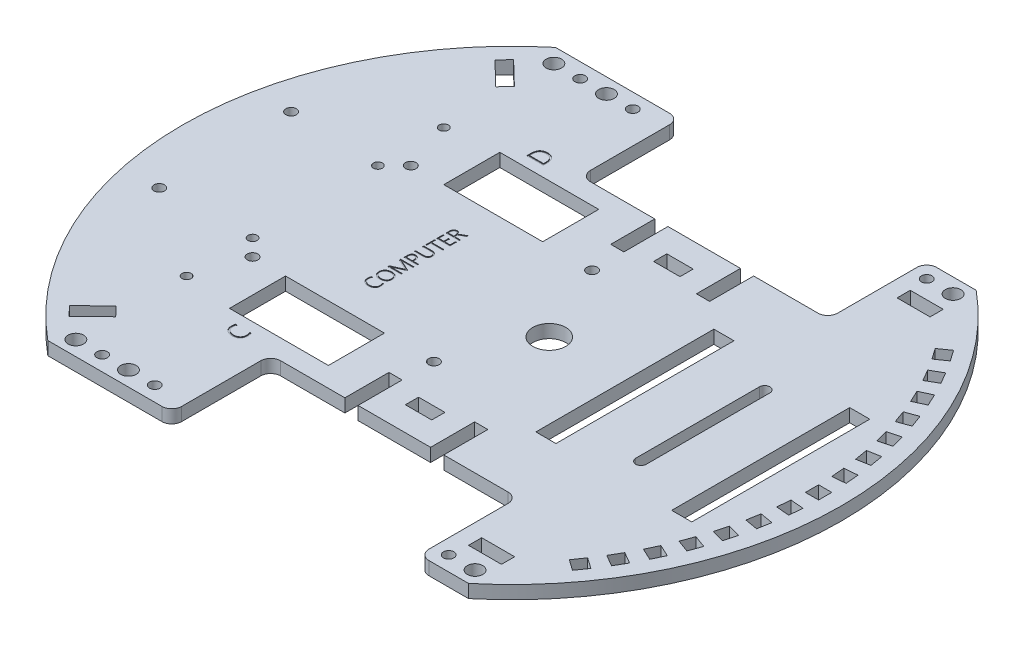
from build123d import *

# Parameters (mm, degrees)
BASIS_DEPTH         = 4
SKETCH2_W           = 4
SKETCH2_H           = 4
MODU_BRACKET_DEPTH  = 4
SKETCH3_R           = 5
SKETCH3_W           = 75
SKETCH3_H           = 30
SKETCH3_W_2         = 8
SKETCH3_H_2         = 4
CUT_EXTRUDE2_DEPTH  = 5
SKETCH4_W           = 6.1
SKETCH4_H           = 54
CUT_EXTRUDE3_DEPTH  = 4
SKETCH5_W           = 4
SKETCH5_H           = 14
CUT_EXTRUDE4_DEPTH  = 4
SKETCH6_W           = 10
SKETCH6_H           = 4
CUT_EXTRUDE5_DEPTH  = 4
SKETCH9_R           = 1.6
SKETCH9_R_2         = 1.375
CUT_EXTRUDE7_DEPTH  = 4
SKETCH10_W          = 30
SKETCH10_H          = 17
CUT_EXTRUDE8_DEPTH  = 4
SKETCH11_R          = 1.6
CUT_EXTRUDE9_DEPTH  = 4
CUT_EXTRUDE15_DEPTH = 0.2
SKETCH21_R          = 2.35
SKETCH21_R_2        = 1.6
CUT_EXTRUDE16_DEPTH = 4
FILLET1_R           = 3


with BuildPart() as part:
    # Sketch1 → Basis (new body)
    with BuildSketch(Plane(origin=(0, 0, 0), x_dir=(1, 0, 0), z_dir=(0, 1, 0))):
        with BuildLine():
            Line((63.804388564, 77), (-63.804388564, 77))
            ThreePointArc((-63.804388564, 77), (-100, 0), (-63.804388564, -77))
            Line((-63.804388564, -77), (63.804388564, -77))
            ThreePointArc((63.804388564, -77), (90.499831095, -42.541515862), (100, 0))
            ThreePointArc((100, 0), (90.499831095, 42.541515862), (63.804388564, 77))
        make_face()
    extrude(amount=BASIS_DEPTH)

    # Sketch2 → Modu bracket (cut)
    with BuildSketch(Plane(origin=(0, 4, 0), x_dir=(1, 0, 0), z_dir=(0, 1, 0))):
        Polygon((90.817009036, -6.191182133), (94.801787829, -6.539805104), (94.453164858, -10.524583897), (90.468386065, -10.175960926), align=None)
        with Locations((93, 0)):
            Rectangle(SKETCH2_W, SKETCH2_H)
        Polygon((89.920805845, -14.335245632), (93.860036857, -15.029838343), (93.165444147, -18.969069355), (89.226213135, -18.274476644), align=None)
        Polygon((88.318211075, -22.370209256), (92.18191438, -23.405485436), (91.1466382, -27.269188741), (87.282934895, -26.233912561), align=None)
        Polygon((86.021421439, -30.23492208), (89.780191922, -31.603002653), (88.412111349, -35.361773136), (84.653340866, -33.993692563), align=None)
        Polygon((83.047916894, -37.86952889), (86.673148042, -39.560001937), (84.982674995, -43.185233085), (81.357443847, -41.494760038), align=None)
        Polygon((79.420327603, -45.21592572), (82.884429218, -47.21592572), (80.884429218, -50.680027335), (77.420327603, -48.680027335), align=None)
        Polygon((75.166261713, -52.218202052), (78.442869891, -54.512507797), (76.148564145, -57.789115975), (72.871955968, -55.494810229), align=None)
        Polygon((90.468386065, 10.175960926), (94.453164858, 10.524583897), (94.801787829, 6.539805104), (90.817009036, 6.191182133), align=None)
        Polygon((89.226213135, 18.274476644), (93.165444147, 18.969069355), (93.860036857, 15.029838343), (89.920805845, 14.335245632), align=None)
        Polygon((87.282934895, 26.233912561), (91.1466382, 27.269188741), (92.18191438, 23.405485436), (88.318211075, 22.370209256), align=None)
        Polygon((84.653340866, 33.993692563), (88.412111349, 35.361773136), (89.780191922, 31.603002653), (86.021421439, 30.23492208), align=None)
        Polygon((81.357443847, 41.494760038), (84.982674995, 43.185233085), (86.673148042, 39.560001937), (83.047916894, 37.86952889), align=None)
        Polygon((77.420327603, 48.680027335), (80.884429218, 50.680027335), (82.884429218, 47.21592572), (79.420327603, 45.21592572), align=None)
        Polygon((72.871955968, 55.494810229), (76.148564145, 57.789115975), (78.44286989, 54.512507797), (75.166261713, 52.218202052), align=None)
    extrude(amount=-MODU_BRACKET_DEPTH, mode=Mode.SUBTRACT)

    # Sketch3 → Cut-Extrude2 (cut, through all)
    with BuildSketch(Plane(origin=(0, 4, 0), x_dir=(1, 0, 0), z_dir=(0, 1, 0))):
        with Locations((11.304388564, 0)):
            Circle(SKETCH3_R)
        with Locations((11.304388564, -62)):
            Rectangle(SKETCH3_W, SKETCH3_H)
        with Locations((11.304388564, 62)):
            Rectangle(SKETCH3_W, SKETCH3_H)
        with Locations((11.304388564, -37.65)):
            Rectangle(SKETCH3_W_2, SKETCH3_H_2)
        with Locations((11.304388564, 37.65)):
            Rectangle(SKETCH3_W_2, SKETCH3_H_2)
    extrude(amount=-CUT_EXTRUDE2_DEPTH, mode=Mode.SUBTRACT)

    # Sketch4 → Cut-Extrude3 (cut)
    with BuildSketch(Plane(origin=(0, 4, 0), x_dir=(1, 0, 0), z_dir=(0, 1, 0))):
        with BuildLine():
            Line((56.282145861, -18.75), (56.282145861, 18.75))
            ThreePointArc((56.282145861, 18.75), (57.882145861, 20.35), (59.482145861, 18.75))
            Line((59.482145861, 18.75), (59.482145861, -18.75))
            ThreePointArc((59.482145861, -18.75), (57.882145861, -20.35), (56.282145861, -18.75))
        make_face()
        with Locations((78.482145861, 0)):
            Rectangle(SKETCH4_W, SKETCH4_H)
        with Locations((37.282145861, 0)):
            Rectangle(SKETCH4_W, SKETCH4_H)
    extrude(amount=-CUT_EXTRUDE3_DEPTH, mode=Mode.SUBTRACT)

    # Sketch5 → Cut-Extrude4 (cut)
    with BuildSketch(Plane(origin=(0, 4, 0), x_dir=(1, 0, 0), z_dir=(0, 1, 0))):
        with Locations((-1.695611436, -40.64)):
            Rectangle(SKETCH5_W, SKETCH5_H)
        with Locations((-1.695611436, 40.64)):
            Rectangle(SKETCH5_W, SKETCH5_H)
        with Locations((24.304388564, 40.64)):
            Rectangle(SKETCH5_W, SKETCH5_H)
        with Locations((24.304388564, -40.64)):
            Rectangle(SKETCH5_W, SKETCH5_H)
    extrude(amount=-CUT_EXTRUDE4_DEPTH, mode=Mode.SUBTRACT)

    # Sketch6 → Cut-Extrude5 (cut)
    with BuildSketch(Plane(origin=(0, 4, 0), x_dir=(1, 0, 0), z_dir=(0, 1, 0))):
        Polygon((-62.518054096, 57.592655881), (-59.739420614, 60.470015082), (-66.932818617, 67.416598787), (-69.711452099, 64.539239585), align=None)
        Polygon((-59.739420614, -60.470015082), (-62.518054096, -57.592655881), (-69.711452099, -64.539239585), (-66.932818617, -67.416598787), align=None)
        with Locations((58.804388564, -65)):
            Rectangle(SKETCH6_W, SKETCH6_H)
        with Locations((58.804388564, 65)):
            Rectangle(SKETCH6_W, SKETCH6_H)
    extrude(amount=-CUT_EXTRUDE5_DEPTH, mode=Mode.SUBTRACT)

    # Sketch9 → Cut-Extrude7 (cut)
    with BuildSketch(Plane(origin=(0, 4, 0), x_dir=(1, 0, 0), z_dir=(0, 1, 0))):
        with Locations((-54.695611436, -24)):
            Circle(SKETCH9_R)
        with Locations((-54.695611436, 24)):
            Circle(SKETCH9_R)
        with Locations((0.304388564, 24)):
            Circle(SKETCH9_R)
        with Locations((0.304388564, -24)):
            Circle(SKETCH9_R)
        with Locations((-59.695611436, 39)):
            Circle(SKETCH9_R_2)
        with Locations((-59.695611436, -19)):
            Circle(SKETCH9_R_2)
        with Locations((-59.695611436, 19)):
            Circle(SKETCH9_R_2)
        with Locations((-59.695611436, -39)):
            Circle(SKETCH9_R_2)
    extrude(amount=-CUT_EXTRUDE7_DEPTH, mode=Mode.SUBTRACT)

    # Sketch10 → Cut-Extrude8 (cut)
    with BuildSketch(Plane(origin=(0, 4, 0), x_dir=(1, 0, 0), z_dir=(0, 1, 0))):
        with Locations((-29.695611436, 32.5)):
            Rectangle(SKETCH10_W, SKETCH10_H)
        with Locations((-29.695611436, -32.5)):
            Rectangle(SKETCH10_W, SKETCH10_H)
    extrude(amount=-CUT_EXTRUDE8_DEPTH, mode=Mode.SUBTRACT)

    # Sketch11 → Cut-Extrude9 (cut)
    with BuildSketch(Plane(origin=(0, 4, 0), x_dir=(1, 0, 0), z_dir=(0, 1, 0))):
        with Locations((-87, -20)):
            Circle(SKETCH11_R)
        with Locations((-87, 20)):
            Circle(SKETCH11_R)
    extrude(amount=-CUT_EXTRUDE9_DEPTH, mode=Mode.SUBTRACT)

    # Sketch19 → Cut-Extrude15 (cut)
    with BuildSketch(Plane(origin=(0, 4, 0), x_dir=(1, 0, 0), z_dir=(0, 1, 0))):
        with BuildLine():
            Line((-27.620116509, 13.789473684), (-28.764030983, 13.189967105))
            add(Edge.make_bspline(
                [(-28.764030983, 13.189967105), (-28.791190547, 13.175211367), (-28.843592501, 13.146741487), (-28.919163135, 13.104737241), (-28.986003035, 13.060475386), (-29.065302202, 13.007064011), (-29.14879643, 12.937773157), (-29.231285032, 12.850032048), (-29.29100747, 12.755802777), (-29.331930074, 12.655323047), (-29.352858252, 12.545282642), (-29.355550789, 12.469106119), (-29.356958614, 12.429276316)],
                knots=[0, 0, 0, 0, 9.2738e-05, 0.00017893, 0.000259224, 0.000333132, 0.000465696, 0.000583857, 0.00069291, 0.000798433, 0.000907458, 0.001026931, 0.001026931, 0.001026931, 0.001026931], degree=3))
            Line((-29.356958614, 12.429276316), (-29.356958614, 11.990953947))
            Line((-29.356958614, 11.990953947), (-27.620116509, 11.990953947))
            Line((-27.620116509, 11.990953947), (-27.620116509, 11.621710526))
            Line((-27.620116509, 11.621710526), (-31.620116509, 11.621710526))
            Line((-31.620116509, 11.621710526), (-31.620116509, 12.768092105))
            add(Edge.make_bspline(
                [(-31.620116509, 12.768092105), (-31.619412802, 12.805142521), (-31.61800612, 12.879204758), (-31.603996193, 12.988790924), (-31.583783484, 13.096991137), (-31.554174196, 13.202303344), (-31.516727853, 13.304310481), (-31.470328532, 13.400701886), (-31.416868601, 13.491838282), (-31.354912712, 13.576650612), (-31.285461998, 13.655539408), (-31.205410049, 13.724282057), (-31.118704721, 13.786903261), (-31.023010732, 13.840130596), (-30.919277559, 13.884676653), (-30.806154605, 13.914164388), (-30.685789781, 13.934075928), (-30.602658625, 13.935796469), (-30.560083614, 13.936677632)],
                knots=[0, 0, 0, 0, 0.000111096, 0.000222076, 0.000330943, 0.000441082, 0.000549846, 0.000656516, 0.00076159, 0.00086637, 0.000971202, 0.001076105, 0.001182219, 0.001291569, 0.001403981, 0.001519889, 0.001641435, 0.001769032, 0.001769032, 0.001769032, 0.001769032], degree=3))
            add(Edge.make_bspline(
                [(-30.560083614, 13.936677632), (-30.52524678, 13.935808295), (-30.456751093, 13.934099017), (-30.356128023, 13.923003872), (-30.260059639, 13.901725085), (-30.167960111, 13.874289553), (-30.08053004, 13.8382729), (-29.99723593, 13.797206657), (-29.920325282, 13.746706883), (-29.847989459, 13.691207927), (-29.780916751, 13.628915963), (-29.718934824, 13.560651523), (-29.663248034, 13.485279984), (-29.611988695, 13.404691872), (-29.566789545, 13.317962075), (-29.527344121, 13.225925663), (-29.494177184, 13.128272064), (-29.47736302, 13.060716966), (-29.46880072, 13.026315789)],
                knots=[0, 0, 0, 0, 0.000104522, 0.000205509, 0.000303094, 0.00039935, 0.00049342, 0.000586468, 0.000677484, 0.000768941, 0.000859722, 0.000951717, 0.001045138, 0.001140505, 0.001237982, 0.00133819, 0.001440653, 0.001546971, 0.001546971, 0.001546971, 0.001546971], degree=3))
            Line((-29.46880072, 13.026315789), (-29.45810993, 13.026315789))
            add(Edge.make_bspline(
                [(-29.45810993, 13.026315789), (-29.445922114, 13.052193734), (-29.421698402, 13.103627058), (-29.372456595, 13.174713523), (-29.313138461, 13.240964793), (-29.242988271, 13.304555691), (-29.162417276, 13.3669573), (-29.069235382, 13.427894442), (-28.965005313, 13.491486215), (-28.889782191, 13.532152562), (-28.850379667, 13.553453947)],
                knots=[0, 0, 0, 0, 8.5692e-05, 0.000170316, 0.000258279, 0.000351989, 0.000453976, 0.000563685, 0.000685822, 0.000820173, 0.000820173, 0.000820173, 0.000820173], degree=3))
            Line((-28.850379667, 13.553453947), (-27.620116509, 14.222039474))
            Line((-27.620116509, 14.222039474), (-27.620116509, 13.789473684))
        make_face()
        with BuildLine():
            Line((-31.304327035, 11.990953947), (-29.672748088, 11.990953947))
            Line((-29.672748088, 11.990953947), (-29.672748088, 12.651315789))
            add(Edge.make_bspline(
                [(-29.672748088, 12.651315789), (-29.673695142, 12.683953649), (-29.675554534, 12.748032928), (-29.685509082, 12.84213515), (-29.706167779, 12.931545043), (-29.732150438, 13.01688928), (-29.764474449, 13.097810772), (-29.805546361, 13.171870215), (-29.8511839, 13.241087224), (-29.905382327, 13.302649763), (-29.964524058, 13.358576827), (-30.028974034, 13.408865386), (-30.100576985, 13.45038428), (-30.17681889, 13.4867416), (-30.258483814, 13.515992112), (-30.345845988, 13.535112857), (-30.437717221, 13.547970319), (-30.500827263, 13.549424438), (-30.532945456, 13.550164474)],
                knots=[0, 0, 0, 0, 9.7948e-05, 0.000192306, 0.000283288, 0.000372771, 0.000459818, 0.00054409, 0.00062643, 0.000708047, 0.000789491, 0.000870418, 0.000952642, 0.001037251, 0.001123603, 0.001212179, 0.001305106, 0.001401411, 0.001401411, 0.001401411, 0.001401411], degree=3))
            add(Edge.make_bspline(
                [(-30.532945456, 13.550164474), (-30.562317905, 13.54966745), (-30.619352905, 13.548702336), (-30.702391246, 13.537331564), (-30.780821481, 13.520674107), (-30.854250942, 13.495618246), (-30.923270113, 13.464591854), (-30.986768722, 13.425183376), (-31.046585396, 13.380355883), (-31.099916405, 13.326861544), (-31.148766241, 13.268224065), (-31.189717006, 13.202212387), (-31.225680587, 13.131179661), (-31.253980376, 13.053167718), (-31.27754426, 12.969188652), (-31.292198524, 12.878409844), (-31.302663751, 12.782041892), (-31.303762829, 12.71576591), (-31.304327035, 12.681743421)],
                knots=[0, 0, 0, 0, 8.8055e-05, 0.000170984, 0.000250995, 0.000328232, 0.000403302, 0.000477488, 0.000551998, 0.000627014, 0.000703565, 0.000780451, 0.000859522, 0.00094201, 0.001028994, 0.001120794, 0.001217516, 0.001319543, 0.001319543, 0.001319543, 0.001319543], degree=3))
            Line((-31.304327035, 12.681743421), (-31.304327035, 11.990953947))
        make_face(mode=Mode.SUBTRACT)
        Polygon((-27.620116509, 8.779605263), (-31.620116509, 8.779605263), (-31.620116509, 10.719572368), (-31.304327035, 10.719572368), (-31.304327035, 9.148848684), (-29.830642825, 9.148848684), (-29.830642825, 10.602796053), (-29.514853351, 10.602796053), (-29.514853351, 9.148848684), (-27.935905983, 9.148848684), (-27.935905983, 10.808388158), (-27.620116509, 10.808388158), align=None)
        Polygon((-31.304327035, 6.970394737), (-27.620116509, 6.970394737), (-27.620116509, 6.601151316), (-31.304327035, 6.601151316), (-31.304327035, 5.454769737), (-31.620116509, 5.454769737), (-31.620116509, 8.119243421), (-31.304327035, 8.119243421), align=None)
        with BuildLine():
            add(Edge.make_bspline(
                [(-29.236892825, 4.854440789), (-29.169420931, 4.853402494), (-29.038628789, 4.85138979), (-28.8490037, 4.834023572), (-28.672588988, 4.805378693), (-28.508606268, 4.766454599), (-28.357803796, 4.714955689), (-28.220231134, 4.651110597), (-28.095143059, 4.577171434), (-27.982746797, 4.491525667), (-27.885576229, 4.392048983), (-27.798894196, 4.283510022), (-27.727135741, 4.162025828), (-27.668862365, 4.029332005), (-27.622335106, 3.8856292), (-27.591297482, 3.729960106), (-27.570869525, 3.5633166), (-27.568635715, 3.448255807), (-27.56748493, 3.388980263)],
                knots=[0, 0, 0, 0, 0.000202385, 0.000392316, 0.000570641, 0.000738186, 0.000897348, 0.001047833, 0.001192394, 0.001332537, 0.001470355, 0.001608552, 0.001748318, 0.00189227, 0.00204259, 0.002200487, 0.002367774, 0.002545527, 0.002545527, 0.002545527, 0.002545527], degree=3))
            add(Edge.make_bspline(
                [(-27.56748493, 3.388980263), (-27.5687221, 3.33245504), (-27.57111973, 3.222909421), (-27.590317717, 3.064109202), (-27.621313036, 2.916217065), (-27.664373714, 2.778796458), (-27.721901342, 2.652696673), (-27.790839288, 2.536952894), (-27.87280915, 2.432061503), (-27.968774519, 2.339646786), (-28.075946263, 2.256783751), (-28.196591568, 2.185777814), (-28.329445125, 2.126186178), (-28.474390198, 2.076398601), (-28.632313936, 2.039157082), (-28.802494325, 2.012506912), (-28.985191317, 1.995782274), (-29.111033044, 1.993683053), (-29.176037562, 1.992598684)],
                knots=[0, 0, 0, 0, 0.000169536, 0.000328559, 0.000479044, 0.000622346, 0.000759622, 0.000893888, 0.001025664, 0.001157677, 0.001292555, 0.001431195, 0.00157657, 0.001728708, 0.001890272, 0.002062652, 0.002245138, 0.002440124, 0.002440124, 0.002440124, 0.002440124], degree=3))
            Line((-29.176037562, 1.992598684), (-31.620116509, 1.992598684))
            Line((-31.620116509, 1.992598684), (-31.620116509, 2.361842105))
            Line((-31.620116509, 2.361842105), (-29.195774404, 2.361842105))
            add(Edge.make_bspline(
                [(-29.195774404, 2.361842105), (-29.142568754, 2.362573228), (-29.039569146, 2.363988593), (-28.890153836, 2.376506741), (-28.751069933, 2.396649339), (-28.622290757, 2.425176486), (-28.503932589, 2.46220281), (-28.395699864, 2.507109372), (-28.297877493, 2.560970495), (-28.209702978, 2.622526529), (-28.132831264, 2.694118943), (-28.065147552, 2.773803127), (-28.008270816, 2.863196203), (-27.962217081, 2.961687282), (-27.926714215, 3.069127594), (-27.901821763, 3.185208036), (-27.885581807, 3.310398901), (-27.884061094, 3.396875885), (-27.883274404, 3.441611842)],
                knots=[0, 0, 0, 0, 0.000159592, 0.000308951, 0.000449444, 0.000580923, 0.000704207, 0.000821047, 0.000931835, 0.001038619, 0.001142788, 0.001246083, 0.001351477, 0.001459634, 0.001571458, 0.001690181, 0.001815338, 0.001949475, 0.001949475, 0.001949475, 0.001949475], degree=3))
            add(Edge.make_bspline(
                [(-27.883274404, 3.441611842), (-27.884136617, 3.48387762), (-27.885805163, 3.5656699), (-27.901081268, 3.684286145), (-27.925010708, 3.795075528), (-27.960936426, 3.897364111), (-28.004982507, 3.992369897), (-28.060762457, 4.078102945), (-28.125542444, 4.156553709), (-28.200552466, 4.226739416), (-28.286518587, 4.287607156), (-28.381246218, 4.341615308), (-28.486825434, 4.385387274), (-28.601536922, 4.423039563), (-28.726814828, 4.449905923), (-28.861321373, 4.470676047), (-29.005852319, 4.483022486), (-29.105564066, 4.484456083), (-29.157123088, 4.485197368)],
                knots=[0, 0, 0, 0, 0.000126741, 0.000245267, 0.000358193, 0.000466124, 0.00056986, 0.000671598, 0.000772048, 0.000874452, 0.00097875, 0.001087383, 0.001200873, 0.001321024, 0.001449112, 0.001584726, 0.001729168, 0.001883828, 0.001883828, 0.001883828, 0.001883828], degree=3))
            Line((-29.157123088, 4.485197368), (-31.620116509, 4.485197368))
            Line((-31.620116509, 4.485197368), (-31.620116509, 4.854440789))
            Line((-31.620116509, 4.854440789), (-29.236892825, 4.854440789))
        make_face()
        with BuildLine():
            Line((-29.199063877, -0.745888158), (-27.620116509, -0.745888158))
            Line((-27.620116509, -0.745888158), (-27.620116509, -1.115131579))
            Line((-27.620116509, -1.115131579), (-31.620116509, -1.115131579))
            Line((-31.620116509, -1.115131579), (-31.620116509, -0.087993421))
            add(Edge.make_bspline(
                [(-31.620116509, -0.087993421), (-31.619249864, -0.037238436), (-31.617564184, 0.061483199), (-31.602211081, 0.204902168), (-31.579035634, 0.339542926), (-31.54514859, 0.464967068), (-31.502539098, 0.58155004), (-31.450715695, 0.688710937), (-31.390399521, 0.786792155), (-31.321150725, 0.87508684), (-31.24338185, 0.95378411), (-31.157131037, 1.022733508), (-31.062332241, 1.081099261), (-30.959283945, 1.128993584), (-30.84853776, 1.166967499), (-30.73002458, 1.193921256), (-30.603808767, 1.20949635), (-30.51736414, 1.211805836), (-30.472912562, 1.212993421)],
                knots=[0, 0, 0, 0, 0.000152218, 0.000296074, 0.000432225, 0.000561692, 0.00068528, 0.000804081, 0.000918189, 0.001030058, 0.001139963, 0.001249388, 0.001360532, 0.00147311, 0.001589619, 0.00171111, 0.001837083, 0.001970431, 0.001970431, 0.001970431, 0.001970431], degree=3))
            add(Edge.make_bspline(
                [(-30.472912562, 1.212993421), (-30.427617592, 1.211997653), (-30.338570172, 1.210040028), (-30.2077284, 1.191278957), (-30.08223177, 1.161198752), (-29.962919221, 1.117973154), (-29.849543048, 1.064768514), (-29.744358205, 0.999667547), (-29.647094982, 0.924051426), (-29.558274495, 0.838162366), (-29.476877343, 0.742643341), (-29.406582971, 0.635765877), (-29.344283681, 0.51976628), (-29.291919207, 0.393942771), (-29.249689054, 0.258901919), (-29.220646476, 0.114756947), (-29.201898522, -0.037881179), (-29.200024799, -0.142759937), (-29.199063877, -0.196546053)],
                knots=[0, 0, 0, 0, 0.000135813, 0.000267001, 0.000395651, 0.00052233, 0.000647032, 0.00077073, 0.000892623, 0.001015924, 0.001140805, 0.001268304, 0.001398915, 0.001535302, 0.001676541, 0.001822664, 0.001975874, 0.002137161, 0.002137161, 0.002137161, 0.002137161], degree=3))
            Line((-29.199063877, -0.196546053), (-29.199063877, -0.745888158))
        make_face()
        with BuildLine():
            Line((-31.304327035, -0.745888158), (-29.514853351, -0.745888158))
            Line((-29.514853351, -0.745888158), (-29.514853351, -0.21875))
            add(Edge.make_bspline(
                [(-29.514853351, -0.21875), (-29.515786323, -0.177344287), (-29.517599845, -0.096859335), (-29.52749163, 0.020446297), (-29.547849006, 0.129646217), (-29.573419649, 0.231833529), (-29.608403875, 0.325424853), (-29.649087462, 0.41249154), (-29.700007194, 0.490340323), (-29.756501561, 0.561954406), (-29.821182758, 0.624232285), (-29.891240705, 0.679436728), (-29.968881322, 0.724460555), (-30.052015982, 0.762959185), (-30.142365467, 0.790956285), (-30.238193723, 0.812908064), (-30.340476404, 0.824990505), (-30.410657532, 0.826519596), (-30.446596772, 0.827302632)],
                knots=[0, 0, 0, 0, 0.000124246, 0.00024151, 0.000352652, 0.00045717, 0.00055708, 0.000651978, 0.000744822, 0.000835495, 0.000925054, 0.001013553, 0.001102407, 0.001193675, 0.001287821, 0.001385582, 0.0014883, 0.001596108, 0.001596108, 0.001596108, 0.001596108], degree=3))
            add(Edge.make_bspline(
                [(-30.446596772, 0.827302632), (-30.481171962, 0.82650802), (-30.548328549, 0.824964619), (-30.645708628, 0.813202697), (-30.736767348, 0.794788225), (-30.82106435, 0.767459309), (-30.898843592, 0.732819341), (-30.970398255, 0.691097492), (-31.033689979, 0.640089567), (-31.091794518, 0.582980756), (-31.141302912, 0.516700137), (-31.185622348, 0.443654546), (-31.222441303, 0.362403508), (-31.252810278, 0.273745888), (-31.275389433, 0.177217374), (-31.292901256, 0.073733918), (-31.302529229, -0.037920409), (-31.303714359, -0.114840117), (-31.304327035, -0.154605263)],
                knots=[0, 0, 0, 0, 0.0001037, 0.00020142, 0.000293837, 0.000381999, 0.000466667, 0.000548892, 0.000629677, 0.000709924, 0.000792657, 0.000877137, 0.000965819, 0.001059703, 0.001157837, 0.001262885, 0.001374342, 0.001493631, 0.001493631, 0.001493631, 0.001493631], degree=3))
            Line((-31.304327035, -0.154605263), (-31.304327035, -0.745888158))
        make_face(mode=Mode.SUBTRACT)
        with BuildLine():
            Line((-27.620116509, -2.487664474), (-30.381629667, -2.487664474))
            add(Edge.make_bspline(
                [(-30.381629667, -2.487664474), (-30.400544836, -2.487430305), (-30.441395185, -2.486924581), (-30.506639106, -2.485223564), (-30.580101736, -2.482665693), (-30.661543465, -2.479610475), (-30.750881399, -2.474362902), (-30.848469177, -2.468619009), (-30.954010253, -2.462086048), (-31.027190579, -2.457262863), (-31.065017825, -2.454769737)],
                knots=[0, 0, 0, 0, 5.6749e-05, 0.000122559, 0.000195792, 0.000277273, 0.000367047, 0.000464257, 0.000570546, 0.000684274, 0.000684274, 0.000684274, 0.000684274], degree=3))
            Line((-31.065017825, -2.454769737), (-31.065017825, -2.465460526))
            add(Edge.make_bspline(
                [(-31.065017825, -2.465460526), (-31.025776089, -2.477948058), (-30.952912142, -2.501134873), (-30.852309258, -2.53509602), (-30.767924741, -2.56427535), (-30.718682034, -2.586326987), (-30.696596772, -2.596217105)],
                knots=[0, 0, 0, 0, 0.000123533, 0.000229376, 0.000318606, 0.000391171, 0.000391171, 0.000391171, 0.000391171], degree=3))
            Line((-30.696596772, -2.596217105), (-27.620116509, -3.983552632))
            Line((-27.620116509, -3.983552632), (-27.620116509, -4.142269737))
            Line((-27.620116509, -4.142269737), (-30.677682298, -5.532894737))
            add(Edge.make_bspline(
                [(-30.677682298, -5.532894737), (-30.703079312, -5.543291408), (-30.758246421, -5.565874942), (-30.8494963, -5.596521383), (-30.955192105, -5.627708413), (-31.030691088, -5.647426283), (-31.070774404, -5.657894737)],
                knots=[0, 0, 0, 0, 8.2311e-05, 0.000178795, 0.000288599, 0.000412874, 0.000412874, 0.000412874, 0.000412874], degree=3))
            Line((-31.070774404, -5.657894737), (-31.070774404, -5.668585526))
            add(Edge.make_bspline(
                [(-31.070774404, -5.668585526), (-31.025011953, -5.665264152), (-30.927535017, -5.658189414), (-30.771999315, -5.653557679), (-30.598216443, -5.648710252), (-30.476206877, -5.648800981), (-30.412057298, -5.648848684)],
                knots=[0, 0, 0, 0, 0.000137633, 0.000293167, 0.000466736, 0.000659172, 0.000659172, 0.000659172, 0.000659172], degree=3))
            Line((-30.412057298, -5.648848684), (-27.620116509, -5.648848684))
            Line((-27.620116509, -5.648848684), (-27.620116509, -6.009868421))
            Line((-27.620116509, -6.009868421), (-31.620116509, -6.009868421))
            Line((-31.620116509, -6.009868421), (-31.620116509, -5.574013158))
            Line((-31.620116509, -5.574013158), (-28.613537562, -4.222861842))
            add(Edge.make_bspline(
                [(-28.613537562, -4.222861842), (-28.581524834, -4.208739712), (-28.517233222, -4.180378038), (-28.418585763, -4.139948293), (-28.316418785, -4.10008824), (-28.24527823, -4.078475981), (-28.208932298, -4.067434211)],
                knots=[0, 0, 0, 0, 0.000104961, 0.000210794, 0.000319847, 0.000433762, 0.000433762, 0.000433762, 0.000433762], degree=3))
            Line((-28.208932298, -4.067434211), (-28.208932298, -4.050164474))
            add(Edge.make_bspline(
                [(-28.208932298, -4.050164474), (-28.244522758, -4.037696078), (-28.312347461, -4.013935068), (-28.412999472, -3.981062246), (-28.511357802, -3.943789375), (-28.576381626, -3.91532077), (-28.610248088, -3.900493421)],
                knots=[0, 0, 0, 0, 0.000113132, 0.000215595, 0.000317622, 0.00042852, 0.00042852, 0.00042852, 0.00042852], degree=3))
            Line((-28.610248088, -3.900493421), (-31.620116509, -2.537828947))
            Line((-31.620116509, -2.537828947), (-31.620116509, -2.124177632))
            Line((-31.620116509, -2.124177632), (-27.620116509, -2.124177632))
            Line((-27.620116509, -2.124177632), (-27.620116509, -2.487664474))
        make_face()
        with BuildLine():
            add(Edge.make_bspline(
                [(-27.56748493, -8.704769737), (-27.569391499, -8.774765058), (-27.573124245, -8.911804256), (-27.602059682, -9.112158924), (-27.651685546, -9.301481244), (-27.71989135, -9.479652608), (-27.805960439, -9.645002095), (-27.905880183, -9.798472538), (-28.020613045, -9.938798401), (-28.149633495, -10.065794373), (-28.29121236, -10.179845704), (-28.446245737, -10.278383132), (-28.612223119, -10.364608025), (-28.789771158, -10.43551106), (-28.976198244, -10.492432526), (-29.170527852, -10.532611082), (-29.371690985, -10.556878902), (-29.508206919, -10.560064235), (-29.577353351, -10.561677632)],
                knots=[0, 0, 0, 0, 0.000209936, 0.00041102, 0.000605699, 0.000795993, 0.000982105, 0.001163895, 0.001344481, 0.00152475, 0.001706097, 0.00188882, 0.002074932, 0.002266431, 0.002461542, 0.002658955, 0.002861025, 0.003068425, 0.003068425, 0.003068425, 0.003068425], degree=3))
            add(Edge.make_bspline(
                [(-29.577353351, -10.561677632), (-29.653349927, -10.560102533), (-29.8021647, -10.557018211), (-30.020540101, -10.53268601), (-30.229177695, -10.49284664), (-30.427159702, -10.435963654), (-30.613839901, -10.365153129), (-30.786387979, -10.277143526), (-30.946184337, -10.176044406), (-31.09179119, -10.05963199), (-31.222264974, -9.928065171), (-31.337916386, -9.782794408), (-31.437889503, -9.623469765), (-31.522850616, -9.451238168), (-31.590926615, -9.265374461), (-31.637681695, -9.066284242), (-31.667352958, -8.855057129), (-31.670918518, -8.71008122), (-31.672748088, -8.635690789)],
                knots=[0, 0, 0, 0, 0.000227944, 0.000446356, 0.000658281, 0.000864435, 0.001063586, 0.001256303, 0.001444512, 0.001629968, 0.001814305, 0.001999249, 0.002185883, 0.002377496, 0.002574434, 0.002778284, 0.002989954, 0.003213034, 0.003213034, 0.003213034, 0.003213034], degree=3))
            add(Edge.make_bspline(
                [(-31.672748088, -8.635690789), (-31.67124688, -8.567047757), (-31.668308481, -8.432688938), (-31.638408186, -8.237090879), (-31.591893154, -8.051930803), (-31.525926338, -7.87790644), (-31.442277248, -7.715926195), (-31.345320997, -7.565103225), (-31.23246003, -7.427717568), (-31.105447371, -7.303308659), (-30.964908698, -7.192091828), (-30.812573203, -7.093791971), (-30.647211282, -7.010508542), (-30.470796051, -6.940796723), (-30.28379346, -6.886138459), (-30.088700577, -6.845307413), (-29.885189434, -6.822476929), (-29.747089552, -6.819134153), (-29.67685993, -6.817434211)],
                knots=[0, 0, 0, 0, 0.000205791, 0.000402806, 0.00059209, 0.000777663, 0.000959721, 0.001138097, 0.001314575, 0.001491942, 0.001670464, 0.001851359, 0.002034882, 0.002225007, 0.002419646, 0.00261867, 0.002822279, 0.003032965, 0.003032965, 0.003032965, 0.003032965], degree=3))
            add(Edge.make_bspline(
                [(-29.67685993, -6.817434211), (-29.602772503, -6.818634133), (-29.457211611, -6.820991642), (-29.243160491, -6.846186405), (-29.03728826, -6.883959814), (-28.840374042, -6.938479092), (-28.65392569, -7.00708156), (-28.478889044, -7.090251653), (-28.317448849, -7.189064503), (-28.169350201, -7.302523076), (-28.034577321, -7.429119226), (-27.915435239, -7.570746299), (-27.812250991, -7.726611023), (-27.73925172, -7.866718376), (-27.688699546, -7.985058754), (-27.657183534, -8.078545929), (-27.628706107, -8.174339801), (-27.60687946, -8.274221774), (-27.58846151, -8.377008132), (-27.576523151, -8.48360186), (-27.568835742, -8.593086926), (-27.567939322, -8.667201387), (-27.56748493, -8.704769737)],
                knots=[0, 0, 0, 0, 0.000222163, 0.000436487, 0.000645681, 0.000849584, 0.001048632, 0.001241007, 0.001430001, 0.001615372, 0.001799783, 0.001983627, 0.002169288, 0.002359456, 0.00245675, 0.002555056, 0.002655254, 0.002756405, 0.002861591, 0.002968391, 0.003078016, 0.003190708, 0.003190708, 0.003190708, 0.003190708], degree=3))
        make_face()
        with BuildLine():
            add(Edge.make_bspline(
                [(-31.356958614, -8.674342105), (-31.355143898, -8.732816249), (-31.351598761, -8.847048325), (-31.326201452, -9.013385769), (-31.282161915, -9.16916344), (-31.222118814, -9.314735807), (-31.146010157, -9.4488428), (-31.057130067, -9.572058472), (-30.95764267, -9.685571411), (-30.84506499, -9.787029068), (-30.720886817, -9.876733382), (-30.586930864, -9.955757965), (-30.442538013, -10.022747843), (-30.288763101, -10.077358824), (-30.127581477, -10.120618048), (-29.960445192, -10.151971034), (-29.788317234, -10.171088609), (-29.671699337, -10.174341542), (-29.612715193, -10.175986842)],
                knots=[0, 0, 0, 0, 0.000175398, 0.000342648, 0.00050328, 0.000659973, 0.000813896, 0.000964751, 0.001115067, 0.001265866, 0.00141835, 0.001573917, 0.001731754, 0.001895109, 0.002062877, 0.002231909, 0.002404821, 0.002581786, 0.002581786, 0.002581786, 0.002581786], degree=3))
            add(Edge.make_bspline(
                [(-29.612715193, -10.175986842), (-29.556491029, -10.175066484), (-29.444917714, -10.17324009), (-29.279319033, -10.157780292), (-29.117666488, -10.129109891), (-28.960013065, -10.091440285), (-28.808723271, -10.040341357), (-28.665590066, -9.977994658), (-28.531116248, -9.904572672), (-28.40673307, -9.818979681), (-28.292764964, -9.721573857), (-28.189728847, -9.612829459), (-28.10107298, -9.490502832), (-28.022810085, -9.357950393), (-27.959962532, -9.212319258), (-27.914816762, -9.054607159), (-27.88830887, -8.884940294), (-27.884985812, -8.768187865), (-27.883274404, -8.708059211)],
                knots=[0, 0, 0, 0, 0.000168658, 0.000334691, 0.000498282, 0.000660839, 0.000820514, 0.00097666, 0.001128665, 0.001279445, 0.001428764, 0.001577701, 0.001727708, 0.001881024, 0.002038679, 0.002202134, 0.002371948, 0.002552274, 0.002552274, 0.002552274, 0.002552274], degree=3))
            add(Edge.make_bspline(
                [(-27.883274404, -8.708059211), (-27.88470807, -8.647652107), (-27.887490488, -8.530415705), (-27.913188039, -8.360482028), (-27.952401035, -8.201363677), (-28.010797478, -8.054436056), (-28.082914641, -7.918933161), (-28.166357189, -7.794100988), (-28.264043768, -7.681900566), (-28.373726667, -7.581420324), (-28.495289608, -7.492507203), (-28.627550834, -7.414525108), (-28.771502244, -7.349880637), (-28.925443597, -7.296652344), (-29.088598956, -7.254897919), (-29.25955776, -7.224683031), (-29.438233351, -7.206068761), (-29.559763529, -7.204119434), (-29.621761246, -7.203125)],
                knots=[0, 0, 0, 0, 0.000181108, 0.000351489, 0.000514445, 0.000671739, 0.000824409, 0.000974263, 0.001121175, 0.001269596, 0.001419603, 0.00157221, 0.00172936, 0.001892168, 0.002060311, 0.002234049, 0.0024126, 0.002598544, 0.002598544, 0.002598544, 0.002598544], degree=3))
            add(Edge.make_bspline(
                [(-29.621761246, -7.203125), (-29.679920195, -7.203891193), (-29.794835079, -7.205405096), (-29.964781771, -7.222941672), (-30.130241965, -7.24873211), (-30.290408158, -7.28537938), (-30.443296115, -7.333474932), (-30.587052244, -7.3936427), (-30.721252017, -7.465276249), (-30.844760229, -7.549315458), (-30.957970378, -7.644918559), (-31.057455298, -7.754581883), (-31.146388244, -7.875416783), (-31.222402527, -8.008861932), (-31.282882135, -8.156033992), (-31.326380167, -8.316441529), (-31.35181394, -8.490967506), (-31.355202724, -8.611755901), (-31.356958614, -8.674342105)],
                knots=[0, 0, 0, 0, 0.000174412, 0.000344616, 0.000511994, 0.000676571, 0.000837042, 0.000992217, 0.001143437, 0.00129261, 0.001439609, 0.001586868, 0.001735726, 0.001888934, 0.002046387, 0.002211773, 0.002386342, 0.00257406, 0.00257406, 0.00257406, 0.00257406], degree=3))
        make_face(mode=Mode.SUBTRACT)
        with BuildLine():
            add(Edge.make_bspline(
                [(-27.783767825, -11.176809211), (-27.76618498, -11.215494683), (-27.730762995, -11.293429522), (-27.688133196, -11.415348176), (-27.650597759, -11.540931297), (-27.620516233, -11.670624823), (-27.596603274, -11.804288767), (-27.57917578, -11.942047536), (-27.569400813, -12.084010924), (-27.568127952, -12.180084265), (-27.56748493, -12.228618421)],
                knots=[0, 0, 0, 0, 0.000127422, 0.000256701, 0.000387064, 0.000520514, 0.000655855, 0.000794272, 0.000936884, 0.00108248, 0.00108248, 0.00108248, 0.00108248], degree=3))
            add(Edge.make_bspline(
                [(-27.56748493, -12.228618421), (-27.569038371, -12.297531549), (-27.572078324, -12.432388709), (-27.601385213, -12.629804555), (-27.646464646, -12.817829133), (-27.711991158, -12.995117561), (-27.793709955, -13.160615701), (-27.889310143, -13.314763856), (-27.999970307, -13.455864471), (-28.124819311, -13.58412833), (-28.263322833, -13.698277649), (-28.41424119, -13.799444458), (-28.577637028, -13.886646555), (-28.752725462, -13.95967529), (-28.93826613, -14.017398819), (-29.132677407, -14.058017314), (-29.335446882, -14.08353078), (-29.473383754, -14.086487524), (-29.543636246, -14.087993421)],
                knots=[0, 0, 0, 0, 0.000206613, 0.000404323, 0.000597396, 0.000785763, 0.000970022, 0.001150291, 0.00132895, 0.001506904, 0.00168622, 0.001866407, 0.002051102, 0.002240942, 0.002434723, 0.00263311, 0.002836095, 0.003046782, 0.003046782, 0.003046782, 0.003046782], degree=3))
            add(Edge.make_bspline(
                [(-29.543636246, -14.087993421), (-29.617730313, -14.08625829), (-29.763653005, -14.082841078), (-29.978520941, -14.055699424), (-30.185495356, -14.012406561), (-30.384143644, -13.951707241), (-30.572068523, -13.873696996), (-30.74832138, -13.780385245), (-30.911875106, -13.672426067), (-31.062306691, -13.549499923), (-31.198167342, -13.411915542), (-31.31922517, -13.260505057), (-31.42385821, -13.094711533), (-31.513647877, -12.916324989), (-31.586263643, -12.724859792), (-31.63478534, -12.520788768), (-31.668040694, -12.306184226), (-31.67115477, -12.159124644), (-31.672748088, -12.083881579)],
                knots=[0, 0, 0, 0, 0.000222224, 0.000437653, 0.000648619, 0.000855942, 0.001059826, 0.001258114, 0.001453356, 0.001646787, 0.001839849, 0.00203237, 0.002227201, 0.002426903, 0.002630666, 0.002839894, 0.003055168, 0.003280713, 0.003280713, 0.003280713, 0.003280713], degree=3))
            add(Edge.make_bspline(
                [(-31.672748088, -12.083881579), (-31.670897229, -12.001550067), (-31.667282377, -11.840751159), (-31.63780903, -11.606292038), (-31.590884835, -11.384633195), (-31.542077068, -11.245189362), (-31.518142825, -11.176809211)],
                knots=[0, 0, 0, 0, 0.000246908, 0.000482227, 0.0007079, 0.00092505, 0.00092505, 0.00092505, 0.00092505], degree=3))
            Line((-31.518142825, -11.176809211), (-31.12505072, -11.176809211))
            add(Edge.make_bspline(
                [(-31.12505072, -11.176809211), (-31.143641976, -11.212482124), (-31.180572647, -11.283344718), (-31.22688425, -11.393325323), (-31.268105931, -11.504352152), (-31.299451025, -11.618201294), (-31.325509063, -11.733367871), (-31.34304242, -11.850477842), (-31.355577105, -11.969300416), (-31.356495618, -12.049308421), (-31.356958614, -12.089638158)],
                knots=[0, 0, 0, 0, 0.000120631, 0.000239627, 0.000357734, 0.000475665, 0.000593586, 0.000711755, 0.000830734, 0.000951667, 0.000951667, 0.000951667, 0.000951667], degree=3))
            add(Edge.make_bspline(
                [(-31.356958614, -12.089638158), (-31.35554338, -12.152233237), (-31.3527811, -12.274407508), (-31.326484414, -12.452129231), (-31.28491744, -12.619316652), (-31.226403282, -12.775507863), (-31.152151694, -12.919798504), (-31.063992082, -13.052107185), (-30.964637401, -13.174336132), (-30.850016422, -13.282550903), (-30.725128985, -13.380226142), (-30.58772004, -13.464142291), (-30.440822993, -13.537594991), (-30.282907181, -13.597588542), (-30.116013416, -13.644129814), (-29.940814732, -13.677660755), (-29.758248418, -13.698871201), (-29.633881428, -13.701147552), (-29.570774404, -13.702302632)],
                knots=[0, 0, 0, 0, 0.00018768, 0.000366318, 0.000537649, 0.000703682, 0.000865513, 0.001023348, 0.001179922, 0.001336967, 0.001495212, 0.001654737, 0.001819132, 0.001987286, 0.002160683, 0.002338255, 0.002521975, 0.002711234, 0.002711234, 0.002711234, 0.002711234], degree=3))
            add(Edge.make_bspline(
                [(-29.570774404, -13.702302632), (-29.513692808, -13.701402748), (-29.400849584, -13.699623791), (-29.234731739, -13.679282876), (-29.073282832, -13.650727482), (-28.918080473, -13.607420052), (-28.769499251, -13.553833815), (-28.62951585, -13.488059638), (-28.500264742, -13.4093193), (-28.379871175, -13.320549276), (-28.271104014, -13.218852955), (-28.173380435, -13.105794927), (-28.08850461, -12.980461384), (-28.014911004, -12.844477085), (-27.95492315, -12.696740349), (-27.913734191, -12.536618281), (-27.887387574, -12.365457523), (-27.884670531, -12.24736062), (-27.883274404, -12.186677632)],
                knots=[0, 0, 0, 0, 0.000171149, 0.000338341, 0.000501413, 0.000662616, 0.000821052, 0.000974817, 0.001125726, 0.001274411, 0.001422786, 0.00157148, 0.001721796, 0.001875968, 0.002034633, 0.002198798, 0.002370927, 0.002552856, 0.002552856, 0.002552856, 0.002552856], degree=3))
            add(Edge.make_bspline(
                [(-27.883274404, -12.186677632), (-27.884017508, -12.139496775), (-27.885484713, -12.046341603), (-27.898509837, -11.909102763), (-27.917472681, -11.77593387), (-27.946984245, -11.64761779), (-27.982523518, -11.522758335), (-28.028310953, -11.40302658), (-28.080512882, -11.286907751), (-28.122265443, -11.213510014), (-28.143142825, -11.176809211)],
                knots=[0, 0, 0, 0, 0.000141507, 0.000279396, 0.00041326, 0.000544739, 0.000674081, 0.000802383, 0.000928975, 0.001055579, 0.001055579, 0.001055579, 0.001055579], degree=3))
            Line((-28.143142825, -11.176809211), (-27.783767825, -11.176809211))
        make_face()
        with BuildLine():
            Line((-34.695611436, 44.211348684), (-39.695611436, 44.211348684))
            Line((-39.695611436, 44.211348684), (-39.695611436, 45.518914474))
            add(Edge.make_bspline(
                [(-39.695611436, 45.518914474), (-39.694028016, 45.622124784), (-39.690954496, 45.822462535), (-39.661764298, 46.113189207), (-39.614232473, 46.384594504), (-39.546458385, 46.636471679), (-39.460163293, 46.86898819), (-39.355552588, 47.082872544), (-39.229170512, 47.275935731), (-39.08455638, 47.450444329), (-38.92016785, 47.603988067), (-38.737634354, 47.738155888), (-38.535925941, 47.850106556), (-38.316113537, 47.941628567), (-38.078662671, 48.014081651), (-37.822229823, 48.063005852), (-37.547972865, 48.094798521), (-37.358808964, 48.098313402), (-37.26140091, 48.100123355)],
                knots=[0, 0, 0, 0, 0.000309554, 0.000600865, 0.000875501, 0.001135338, 0.001382222, 0.001618518, 0.001848039, 0.002072841, 0.002296837, 0.002521152, 0.002750794, 0.002987147, 0.003234286, 0.003494148, 0.003769319, 0.004061441, 0.004061441, 0.004061441, 0.004061441], degree=3))
            add(Edge.make_bspline(
                [(-37.26140091, 48.100123355), (-37.167075162, 48.097995168), (-36.981904986, 48.093817339), (-36.710898489, 48.05973204), (-36.453389719, 48.001591681), (-36.209290545, 47.923106141), (-35.980319263, 47.821964994), (-35.767392152, 47.700941181), (-35.573018259, 47.557520975), (-35.395166391, 47.395613637), (-35.23569714, 47.214200992), (-35.094541819, 47.014279103), (-34.974601908, 46.795272239), (-34.873521667, 46.558839555), (-34.793590841, 46.305822001), (-34.735848748, 46.036427453), (-34.701864672, 45.751425086), (-34.697725489, 45.556013643), (-34.695611436, 45.456208882)],
                knots=[0, 0, 0, 0, 0.000282915, 0.000555389, 0.000817744, 0.001073907, 0.00132336, 0.001567401, 0.001807134, 0.002046525, 0.002287605, 0.002530311, 0.002779224, 0.003035277, 0.003300562, 0.003573961, 0.00386072, 0.00416007, 0.00416007, 0.00416007, 0.00416007], degree=3))
            Line((-34.695611436, 45.456208882), (-34.695611436, 44.211348684))
        make_face()
        with BuildLine():
            Line((-39.300874594, 44.672902961), (-35.090348278, 44.672902961))
            Line((-35.090348278, 44.672902961), (-35.090348278, 45.435649671))
            add(Edge.make_bspline(
                [(-35.090348278, 45.435649671), (-35.092264721, 45.51896896), (-35.096004515, 45.681560275), (-35.121049529, 45.919105243), (-35.166835477, 46.142403539), (-35.227758287, 46.352413504), (-35.307486009, 46.546932998), (-35.401581379, 46.727993393), (-35.515780934, 46.891595265), (-35.644837138, 47.041004206), (-35.790233697, 47.174081113), (-35.95236912, 47.290428092), (-36.13112557, 47.388776403), (-36.325290758, 47.471295509), (-36.53501234, 47.536127023), (-36.760194069, 47.581787244), (-37.000267616, 47.609973318), (-37.16537801, 47.613246548), (-37.250093344, 47.614925987)],
                knots=[0, 0, 0, 0, 0.000249966, 0.000487789, 0.000715396, 0.000932996, 0.001142786, 0.001345114, 0.001543861, 0.001739879, 0.001936329, 0.002133741, 0.002337124, 0.00254715, 0.002765644, 0.002994464, 0.003235582, 0.003489656, 0.003489656, 0.003489656, 0.003489656], degree=3))
            add(Edge.make_bspline(
                [(-37.250093344, 47.614925987), (-37.333072324, 47.613412785), (-37.493937254, 47.610479259), (-37.727195394, 47.586051633), (-37.943984094, 47.543522557), (-38.145656207, 47.487091443), (-38.33089935, 47.411384917), (-38.500616913, 47.320004545), (-38.654029659, 47.21139378), (-38.791208965, 47.085742043), (-38.911680903, 46.943173838), (-39.016458736, 46.784058473), (-39.104958946, 46.608463737), (-39.176514853, 46.41587341), (-39.233126583, 46.207410348), (-39.272584547, 45.982396502), (-39.296287369, 45.740778976), (-39.299312341, 45.574137828), (-39.300874594, 45.488075658)],
                knots=[0, 0, 0, 0, 0.000248902, 0.000482528, 0.000702475, 0.00091103, 0.001109748, 0.001301558, 0.001488096, 0.00167217, 0.001858151, 0.002046607, 0.002242449, 0.002446742, 0.002661949, 0.002889603, 0.003131304, 0.003389454, 0.003389454, 0.003389454, 0.003389454], degree=3))
            Line((-39.300874594, 45.488075658), (-39.300874594, 44.672902961))
        make_face(mode=Mode.SUBTRACT)
        with BuildLine():
            add(Edge.make_bspline(
                [(-34.900175581, -44.214432566), (-34.878197024, -44.262789407), (-34.833919544, -44.360207956), (-34.780632295, -44.512606272), (-34.733712998, -44.669585174), (-34.696111091, -44.831702081), (-34.666219892, -44.998782011), (-34.644435525, -45.170980473), (-34.632216816, -45.348434708), (-34.63062574, -45.468526383), (-34.629821963, -45.529194079)],
                knots=[0, 0, 0, 0, 0.000159277, 0.000320877, 0.00048383, 0.000650642, 0.000819819, 0.00099284, 0.001171105, 0.0013531, 0.0013531, 0.0013531, 0.0013531], degree=3))
            add(Edge.make_bspline(
                [(-34.629821963, -45.529194079), (-34.631763764, -45.615335488), (-34.635563705, -45.783906939), (-34.672197317, -46.030676747), (-34.728546607, -46.265707469), (-34.810454747, -46.487318004), (-34.912603244, -46.694190678), (-35.032103479, -46.886875873), (-35.170428683, -47.063251641), (-35.326489939, -47.223581465), (-35.499619342, -47.366268114), (-35.688267288, -47.492726625), (-35.892512085, -47.601729246), (-36.111372627, -47.693015165), (-36.343298463, -47.765169576), (-36.586312559, -47.815942695), (-36.839774403, -47.847834527), (-37.012195492, -47.851530458), (-37.100011107, -47.853412829)],
                knots=[0, 0, 0, 0, 0.000258266, 0.000505404, 0.000746745, 0.000982204, 0.001212527, 0.001437864, 0.001661187, 0.001883631, 0.002107776, 0.002333009, 0.002563877, 0.002801178, 0.003043404, 0.003291388, 0.003545119, 0.003808478, 0.003808478, 0.003808478, 0.003808478], degree=3))
            add(Edge.make_bspline(
                [(-37.100011107, -47.853412829), (-37.192628691, -47.851243915), (-37.375032057, -47.846972401), (-37.643616976, -47.813045333), (-37.902334995, -47.758929254), (-38.150645355, -47.683055104), (-38.385551453, -47.585542298), (-38.605867524, -47.468902609), (-38.810309682, -47.333953637), (-38.998349164, -47.180295956), (-39.168174978, -47.00831548), (-39.319497263, -46.819052374), (-39.450288562, -46.611810469), (-39.562525646, -46.388827289), (-39.653295354, -46.149495793), (-39.713947475, -45.894407013), (-39.755516668, -45.626151335), (-39.759409263, -45.442326858), (-39.76140091, -45.348273026)],
                knots=[0, 0, 0, 0, 0.00027778, 0.000547066, 0.000810773, 0.001069928, 0.001324783, 0.001572643, 0.001816694, 0.002058484, 0.002299812, 0.002540462, 0.002784002, 0.003033629, 0.003288333, 0.003549868, 0.00381896, 0.004100891, 0.004100891, 0.004100891, 0.004100891], degree=3))
            add(Edge.make_bspline(
                [(-39.76140091, -45.348273026), (-39.759087336, -45.245358637), (-39.754568772, -45.044360002), (-39.717727088, -44.7512861), (-39.659071844, -44.474212546), (-39.598062134, -44.299907755), (-39.568144331, -44.214432566)],
                knots=[0, 0, 0, 0, 0.000308635, 0.000602784, 0.000884875, 0.001156313, 0.001156313, 0.001156313, 0.001156313], degree=3))
            Line((-39.568144331, -44.214432566), (-39.076779199, -44.214432566))
            add(Edge.make_bspline(
                [(-39.076779199, -44.214432566), (-39.10001827, -44.259023708), (-39.146181609, -44.34760195), (-39.204071112, -44.485077707), (-39.255598213, -44.623861242), (-39.294779581, -44.766172671), (-39.327352129, -44.910130892), (-39.349268824, -45.056518355), (-39.364937181, -45.205046573), (-39.366085323, -45.305056579), (-39.366664068, -45.35546875)],
                knots=[0, 0, 0, 0, 0.000150788, 0.000299534, 0.000447167, 0.000594582, 0.000741982, 0.000889694, 0.001038418, 0.001189584, 0.001189584, 0.001189584, 0.001189584], degree=3))
            add(Edge.make_bspline(
                [(-39.366664068, -45.35546875), (-39.364895025, -45.433712599), (-39.361442175, -45.586430438), (-39.328571317, -45.808582591), (-39.2766126, -46.017566867), (-39.203469903, -46.212805881), (-39.110655417, -46.393169182), (-39.000455902, -46.558555034), (-38.876262552, -46.711341218), (-38.732986327, -46.846609682), (-38.576877031, -46.96870373), (-38.40511585, -47.073598917), (-38.221494541, -47.165414792), (-38.024099776, -47.24040673), (-37.81548257, -47.298583321), (-37.596484215, -47.340496997), (-37.368276322, -47.367010053), (-37.212817585, -47.369855493), (-37.133933805, -47.371299342)],
                knots=[0, 0, 0, 0, 0.0002346, 0.000457897, 0.000672061, 0.000879602, 0.001081891, 0.001279185, 0.001474903, 0.001671208, 0.001869015, 0.002068421, 0.002273915, 0.002484108, 0.002700854, 0.002922819, 0.003152469, 0.003389043, 0.003389043, 0.003389043, 0.003389043], degree=3))
            add(Edge.make_bspline(
                [(-37.133933805, -47.371299342), (-37.062581809, -47.370174488), (-36.92152778, -47.367950792), (-36.713880473, -47.342524647), (-36.512069341, -47.306830406), (-36.318066391, -47.252696118), (-36.132339863, -47.185713321), (-35.957360613, -47.1034956), (-35.795796727, -47.005070178), (-35.645304769, -46.894107647), (-35.509345818, -46.766987247), (-35.387191343, -46.625664711), (-35.281096562, -46.468997783), (-35.189104555, -46.299017409), (-35.114119737, -46.114346489), (-35.062633539, -45.914193904), (-35.029700267, -45.700242956), (-35.026303963, -45.552621827), (-35.024558805, -45.476768092)],
                knots=[0, 0, 0, 0, 0.000213937, 0.000422927, 0.000626766, 0.00082827, 0.001026315, 0.001218521, 0.001407157, 0.001593013, 0.001778482, 0.00196435, 0.002152245, 0.002344959, 0.002543292, 0.002748498, 0.002963659, 0.003191071, 0.003191071, 0.003191071, 0.003191071], degree=3))
            add(Edge.make_bspline(
                [(-35.024558805, -45.476768092), (-35.025487685, -45.417792021), (-35.027321692, -45.301348057), (-35.043603097, -45.129799506), (-35.067306652, -44.96333839), (-35.104196106, -44.802943291), (-35.148620197, -44.646868972), (-35.205854491, -44.497204278), (-35.271106903, -44.352055741), (-35.323297604, -44.260308571), (-35.349394331, -44.214432566)],
                knots=[0, 0, 0, 0, 0.000176884, 0.000349244, 0.000516575, 0.000680923, 0.000842601, 0.001002979, 0.001161218, 0.001319474, 0.001319474, 0.001319474, 0.001319474], degree=3))
            Line((-35.349394331, -44.214432566), (-34.900175581, -44.214432566))
        make_face()
    extrude(amount=-CUT_EXTRUDE15_DEPTH, mode=Mode.SUBTRACT)

    # Sketch21 → Cut-Extrude16 (cut)
    with BuildSketch(Plane(origin=(0, 4, 0), x_dir=(1, 0, 0), z_dir=(0, 1, 0))):
        with Locations((-59.804388564, -72.5)):
            Circle(SKETCH21_R)
        with Locations((-43.844388564, -72.5)):
            Circle(SKETCH21_R)
        with Locations((61.284388564, -72.5)):
            Circle(SKETCH21_R)
        with Locations((61.284388564, 72.5)):
            Circle(SKETCH21_R)
        with Locations((-43.844388564, 72.5)):
            Circle(SKETCH21_R)
        with Locations((-59.804388564, 72.5)):
            Circle(SKETCH21_R)
        with Locations((-51.824388564, -72.5)):
            Circle(SKETCH21_R_2)
        with Locations((-35.864388564, -72.5)):
            Circle(SKETCH21_R_2)
        with Locations((53.304388564, -72.5)):
            Circle(SKETCH21_R_2)
        with Locations((53.304388564, 72.5)):
            Circle(SKETCH21_R_2)
        with Locations((-35.864388564, 72.5)):
            Circle(SKETCH21_R_2)
        with Locations((-51.824388564, 72.5)):
            Circle(SKETCH21_R_2)
    extrude(amount=-CUT_EXTRUDE16_DEPTH, mode=Mode.SUBTRACT)

    # Fillet1
    fillet1_edges = [part.edges().sort_by_distance(p)[0] for p in [
        (48.804388564, 2, 77),
        (-26.195611436, 2, 77),
        (-26.195611436, 2, 47),
        (48.804388564, 2, 47),
        (48.804388564, 2, -77),
        (48.804388564, 2, -47),
        (-26.195611436, 2, -47),
        (-26.195611436, 2, -77),
    ]]
    fillet(fillet1_edges, radius=FILLET1_R)


solid = part.part
